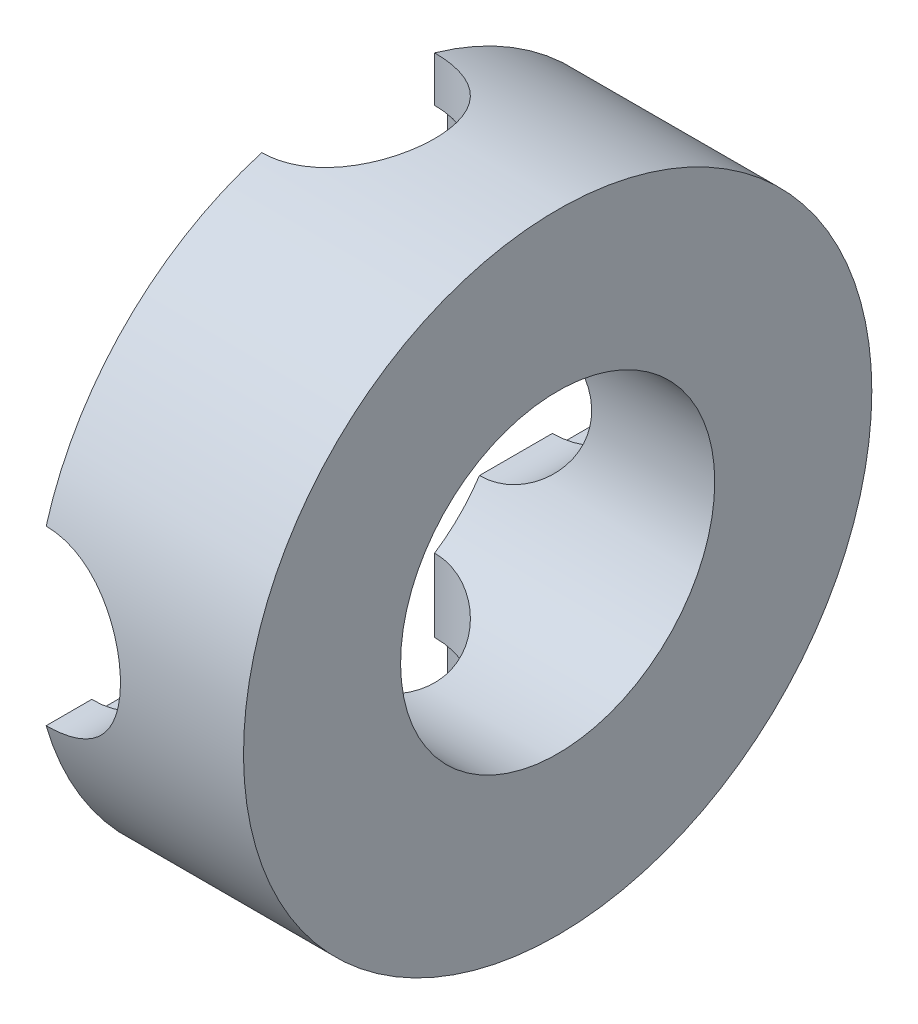
from build123d import *

# Parameters (mm, degrees)
SKETCH1_R           = 30
SKETCH1_R_2         = 15
BOSS_EXTRUDE1_DEPTH = 40
SKETCH2_R           = 9.5
CUT_EXTRUDE1_DEPTH  = 2.5
SKETCH3_R           = 8.25
CUT_EXTRUDE2_DEPTH  = 15
CIRPATTERN1_COUNT   = 4


with BuildPart() as part:
    # Sketch1 → Boss-Extrude1 (new body)
    with BuildSketch(Plane(origin=(0, 0, 0), x_dir=(0, 0, -1), z_dir=(1, 0, 0))):
        Circle(SKETCH1_R)
        Circle(SKETCH1_R_2, mode=Mode.SUBTRACT)
    extrude(amount=BOSS_EXTRUDE1_DEPTH)

    # Sketch2 → Cut-Extrude1 (cut, symmetric)
    with BuildSketch(Plane.XY.offset(22)):
        with Locations((20, 0)):
            Circle(SKETCH2_R)
    cut_extrude1 = extrude(amount=CUT_EXTRUDE1_DEPTH, both=True, mode=Mode.SUBTRACT)

    # Sketch3 → Cut-Extrude2 (cut, symmetric)
    with BuildSketch(Plane.XY.offset(22)):
        with Locations((20, 0)):
            Circle(SKETCH3_R)
    cut_extrude2 = extrude(amount=CUT_EXTRUDE2_DEPTH, both=True, mode=Mode.SUBTRACT)

    # CirPattern1: Cut-Extrude1, Cut-Extrude2 ×4 about axis
    cirpattern1_axis = Axis((0, 0, 0), (1, 0, 0))
    for i in range(1, CIRPATTERN1_COUNT):
        add(cut_extrude1.rotate(cirpattern1_axis, i * 360 / CIRPATTERN1_COUNT), mode=Mode.SUBTRACT)
        add(cut_extrude2.rotate(cirpattern1_axis, i * 360 / CIRPATTERN1_COUNT), mode=Mode.SUBTRACT)


with BuildPart() as body_2:
    # Split2: the piece on the far side of the plane
    add(part.part)
    split(bisect_by=Plane(origin=(20, 0, 0), x_dir=(0, 0, 1), z_dir=(1, 0, 0)), keep=Keep.BOTTOM)


with BuildPart() as part_1:
    add(part.part)

    # Split2
    split(bisect_by=Plane(origin=(20, 0, 0), x_dir=(0, 0, 1), z_dir=(1, 0, 0)), keep=Keep.TOP)


solid = part_1.part
